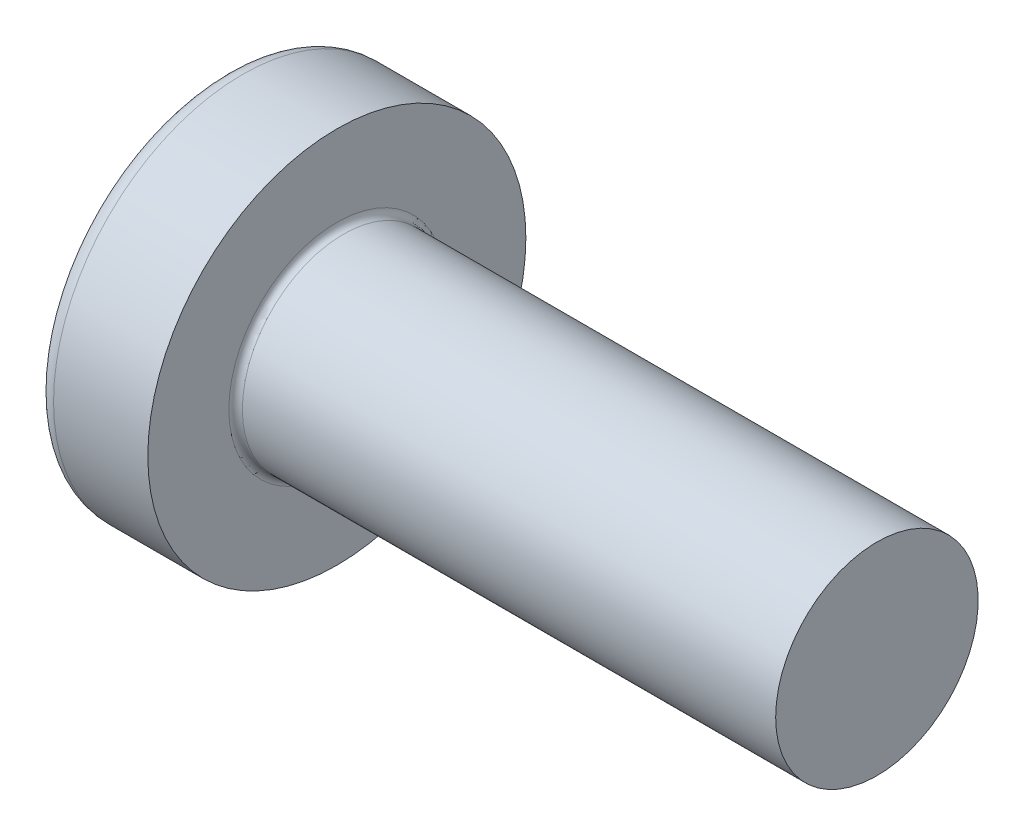
from build123d import *

# Parameters (mm, degrees)
FILLET1_R    = 0.1
SKETCH3_W    = 0.74
SKETCH3_H    = 2.8
SKETCH4_W    = 0.74
SKETCH4_H    = 1.054964432
RECPAT_COUNT = 2
RECPAT_ANGLE = 90


with BuildPart() as part:
    # BodySke → Base-Revolve (revolve)
    with BuildSketch(Plane.XY):
        with BuildLine():
            Line((2.4, 1.5), (2.4, 2.8))
            Line((2.4, 2.8), (1.003501533, 2.8))
            ThreePointArc((1.003501533, 2.8), (0.873295971, 2.76653015), (0.775371599, 2.674418605))
            ThreePointArc((0.775371599, 2.674418605), (0.197753546, 1.392274756), (0, 0))
            Line((0, 0), (10.4, 0))
            Line((10.4, 0), (10.4, 1.5))
            Line((10.4, 1.5), (2.4, 1.5))
        make_face()
    revolve(axis=Axis((-25.4, 0, 0), (1, 0, 0)))

    # Fillet1
    fillet1_edges = [part.edges().sort_by_distance(p)[0] for p in [
        (2.4, -1.5, 0),
    ]]
    fillet(fillet1_edges, radius=FILLET1_R)

    # Sketch3 → Recess section 0
    with BuildSketch(Plane(origin=(0, 0, 0), x_dir=(0, 0, -1), z_dir=(1, 0, 0))):
        Rectangle(SKETCH3_W, SKETCH3_H)
    # Sketch4 → Recess section 1
    with BuildSketch(Plane(origin=(1.75, 0, 0), x_dir=(0, 0, -1), z_dir=(1, 0, 0))):
        Rectangle(SKETCH4_W, SKETCH4_H)
    recess = loft(mode=Mode.SUBTRACT)

    # RecPat: Recess ×2 about axis
    recpat_axis = Axis((0, 0, 0), (1, 0, 0))
    for i in range(1, RECPAT_COUNT):
        add(recess.rotate(recpat_axis, i * RECPAT_ANGLE / (RECPAT_COUNT - 1)), mode=Mode.SUBTRACT)

    # RecCorSke → RecessCore (revolve, cut)
    with BuildSketch(Plane.XY):
        Polygon((0, 0), (0, 0.678371921), (1.75, 0.556), (1.930655351, 0), align=None)
    revolve(axis=Axis((-3.175, 0, 0), (1, 0, 0)), mode=Mode.SUBTRACT)


solid = part.part
